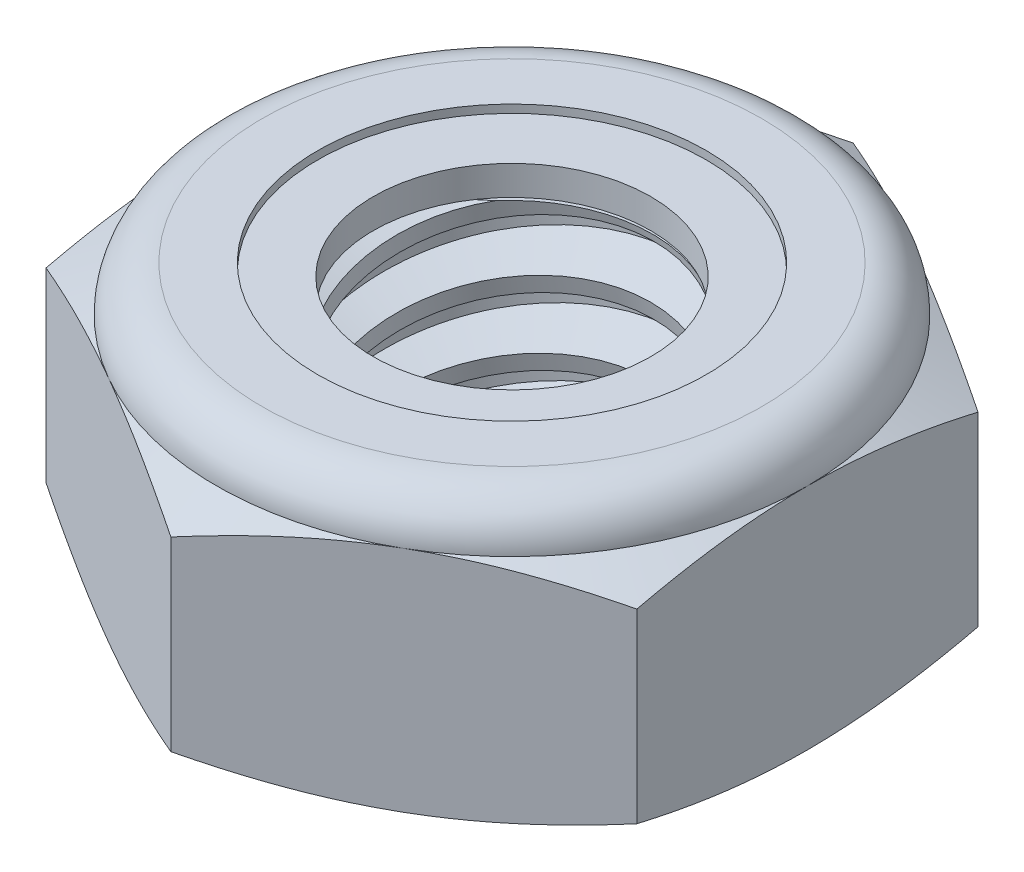
from build123d import *

# Parameters (mm, degrees)
EXTRUDE1_DEPTH      = 5.159375
SKETCH2_W           = 3.175
SKETCH2_H           = 5.159375
LPATTERN1_COUNT     = 4
LPATTERN1_PITCH     = 1.27
LPATTERN1_COL_COUNT = 2
LPATTERN1_COL_PITCH = 1.27


with BuildPart() as part:
    # Sketch1 → Extrude1 (new body)
    with BuildSketch(Plane(origin=(0, 0, 0), x_dir=(1, 0, 0), z_dir=(0, 1, 0))):
        Polygon((0, 6.415804866), (-5.55625, 3.207902433), (-5.55625, -3.207902433), (0, -6.415804866), (5.55625, -3.207902433), (5.55625, 3.207902433), align=None)
    extrude(amount=EXTRUDE1_DEPTH)

    # Sketch4 → Cut-Revolve2 (revolve, cut)
    with BuildSketch(Plane(origin=(0, 0, 0), x_dir=(0, 0, -1), z_dir=(1, 0, 0))):
        Polygon((0, 5.159375), (3.175, 5.159375), (2.609908356, 4.895868439), (2.609908356, 0.263506561), (3.175, 0), (0, 0), align=None)
    revolve(axis=Axis((0, 5.159375, 0), (0, 1, 0)), mode=Mode.SUBTRACT)


with BuildPart() as body_2:
    # Sketch2 → Revolve1 (revolve)
    with BuildSketch(Plane(origin=(0, 0, 0), x_dir=(0, 0, -1), z_dir=(1, 0, 0))):
        with Locations((1.5875, 2.5796875)):
            Rectangle(SKETCH2_W, SKETCH2_H)
    revolve(axis=Axis((0, -3.175, 0), (0, 1, 0)))

    # Sketch3 → Cut-Revolve1 (revolve, cut)
    with BuildSketch(Plane(origin=(0, 0, 0), x_dir=(0, 0, -1), z_dir=(1, 0, 0))):
        Polygon((3.206133436, 5.003707818), (3.424067492, 3.914037542), (2.672175229, 4.168393763), (2.609908356, 4.479728128), align=None)
    cut_revolve1 = revolve(axis=Axis((0, 5.159375, 0.272704483), (0, -0.980580676, -0.196116135)), mode=Mode.SUBTRACT)

    # LPattern1: Cut-Revolve1 ×4
    with Locations(*[(0, -i * LPATTERN1_PITCH, 0) for i in range(1, LPATTERN1_COUNT)]):
        add(cut_revolve1, mode=Mode.SUBTRACT)

    # LPattern1 col: Cut-Revolve1 ×2
    with Locations(*[(0, i * LPATTERN1_COL_PITCH, 0) for i in range(1, LPATTERN1_COL_COUNT)]):
        add(cut_revolve1, mode=Mode.SUBTRACT)


with BuildPart() as part_1:
    add(part.part)

    # Combine1: cut body 2
    add(body_2.part, mode=Mode.SUBTRACT)

    # Sketch5 → Cut-Revolve3 (revolve, cut)
    with BuildSketch(Plane(origin=(0, 0, 0), x_dir=(0, 0, -1), z_dir=(1, 0, 0))):
        with BuildLine():
            Line((0, 0), (5.55625, 0))
            Line((5.55625, 0), (6.415804866, 0.400817017))
            Line((6.415804866, 0.400817017), (6.415804866, 3.89866215))
            Line((6.415804866, 3.89866215), (5.55625, 4.299479167))
            ThreePointArc((5.55625, 4.299479167), (5.304392342, 4.907517342), (4.696354167, 5.159375))
            Line((4.696354167, 5.159375), (4.696354167, 6.429375))
            Line((4.696354167, 6.429375), (7.685804866, 6.429375))
            Line((7.685804866, 6.429375), (7.685804866, -1.27))
            Line((7.685804866, -1.27), (0, -1.27))
            Line((0, -1.27), (0, 0))
        make_face()
    revolve(axis=Axis((0, 0, 0), (0, 1, 0)), mode=Mode.SUBTRACT)

    # Sketch6 → Cut-Revolve4 (revolve, cut)
    with BuildSketch(Plane(origin=(0, 0, 0), x_dir=(0, 0, -1), z_dir=(1, 0, 0))):
        with BuildLine():
            Line((0, 4.299479167), (5.40385, 4.299479167))
            ThreePointArc((5.40385, 4.299479167), (5.196629268, 4.799754268), (4.696354167, 5.006975))
            Line((4.696354167, 5.006975), (3.653131261, 5.006975))
            Line((3.653131261, 5.006975), (3.653131261, 6.429375))
            Line((3.653131261, 6.429375), (0, 6.429375))
            Line((0, 6.429375), (0, 4.299479167))
        make_face()
    revolve(axis=Axis((0, 6.429375, 0), (0, 1, 0)), mode=Mode.SUBTRACT)


with BuildPart() as body_2_2:
    # Sketch7 → Revolve2 (revolve)
    with BuildSketch(Plane(origin=(0, 0, 0), x_dir=(0, 0, -1), z_dir=(1, 0, 0))):
        with BuildLine():
            Line((2.609908356, 4.375679167), (5.3230343, 4.375679167))
            ThreePointArc((5.3230343, 4.375679167), (5.114940888, 4.772046184), (4.696354167, 4.930775))
            Line((4.696354167, 4.930775), (2.609908356, 4.930775))
            Line((2.609908356, 4.930775), (2.609908356, 4.375679167))
        make_face()
    revolve(axis=Axis((0, 4.375679167, 0), (0, 1, 0)))


solid = Compound([part_1.part, body_2_2.part])
